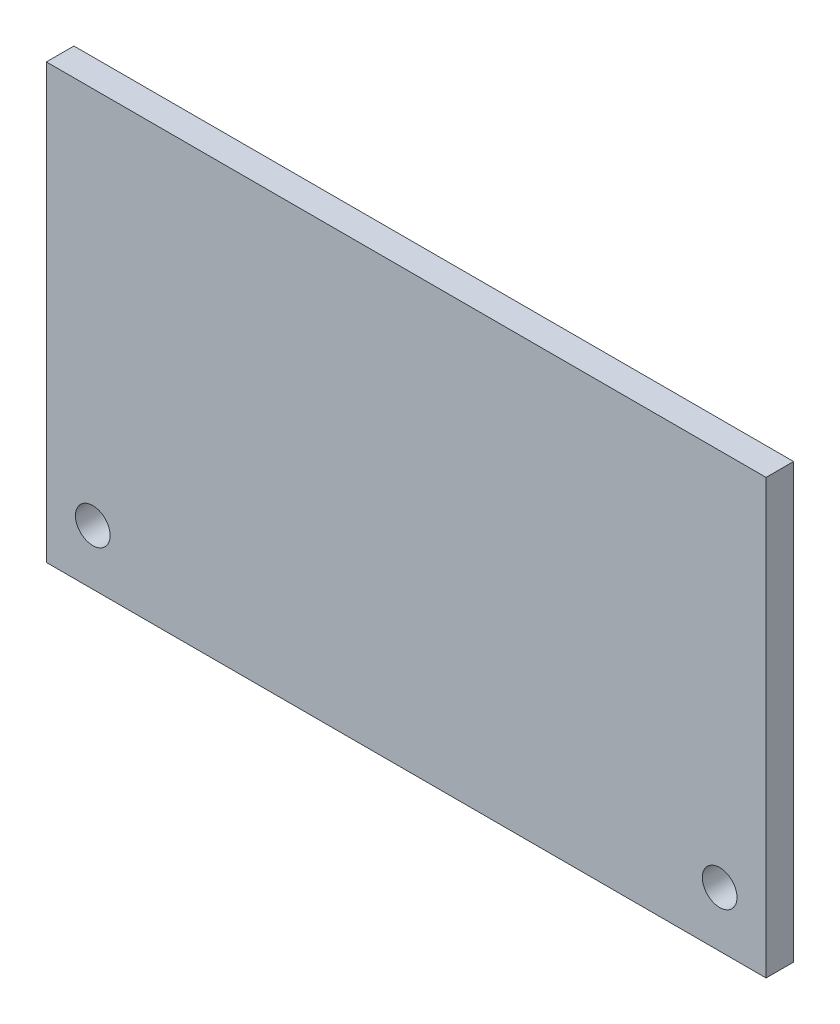
from build123d import *

# Parameters (mm, degrees)
SKETCH1_W           = 166
SKETCH1_H           = 100
BOSS_EXTRUDE1_DEPTH = 6.35
SKETCH2_R           = 4
CUT_EXTRUDE1_DEPTH  = 6.35


with BuildPart() as part:
    # Sketch1 → Boss-Extrude1 (new body)
    with BuildSketch(Plane.XY):
        Rectangle(SKETCH1_W, SKETCH1_H)
    extrude(amount=BOSS_EXTRUDE1_DEPTH)

    # Sketch2 → Cut-Extrude1 (cut)
    with BuildSketch(Plane.XY.offset(6.35)):
        with Locations((-72.3, -37.27)):
            Circle(SKETCH2_R)
        with Locations((72.3, -37.27)):
            Circle(SKETCH2_R)
    extrude(amount=-CUT_EXTRUDE1_DEPTH, mode=Mode.SUBTRACT)


solid = part.part
